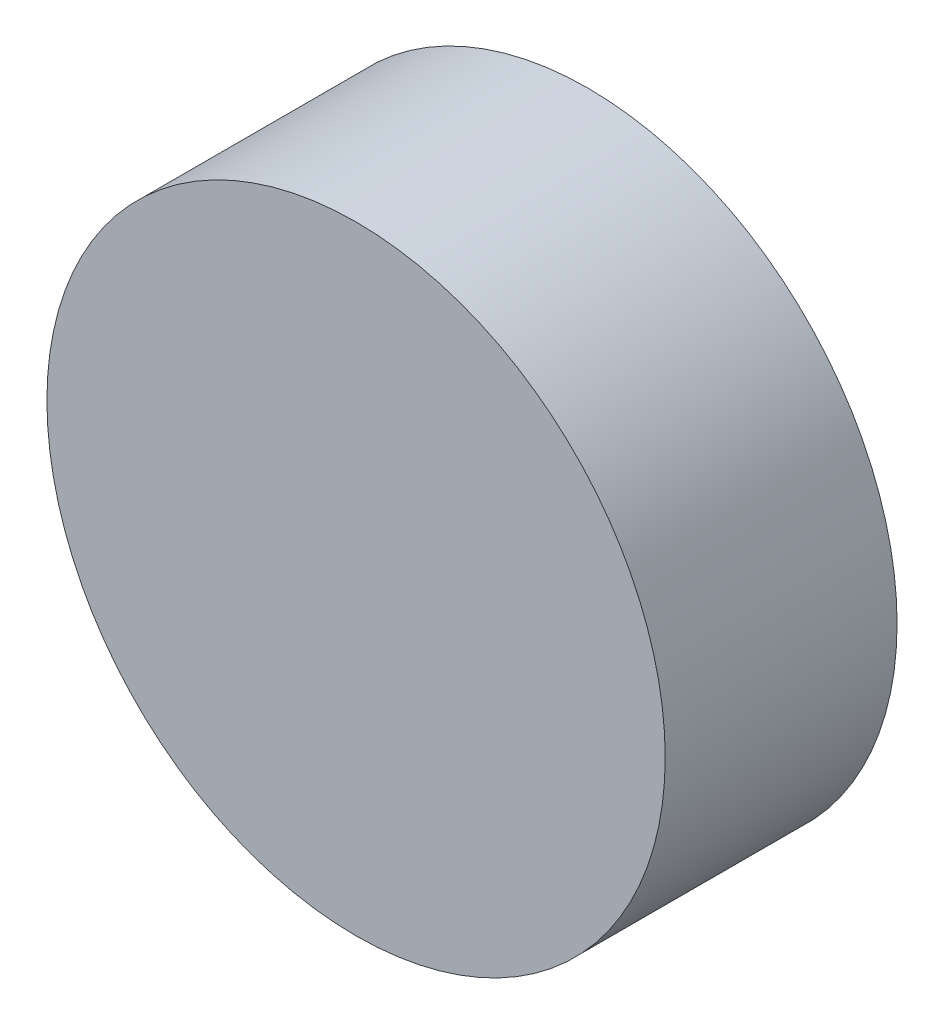
from build123d import *

# Parameters (mm, degrees)
SKETCH1_R           = 4
BOSS_EXTRUDE1_DEPTH = 3


with BuildPart() as part:
    # Sketch1 → Boss-Extrude1 (new body)
    with BuildSketch(Plane.XY):
        Circle(SKETCH1_R)
    extrude(amount=BOSS_EXTRUDE1_DEPTH)


solid = part.part
